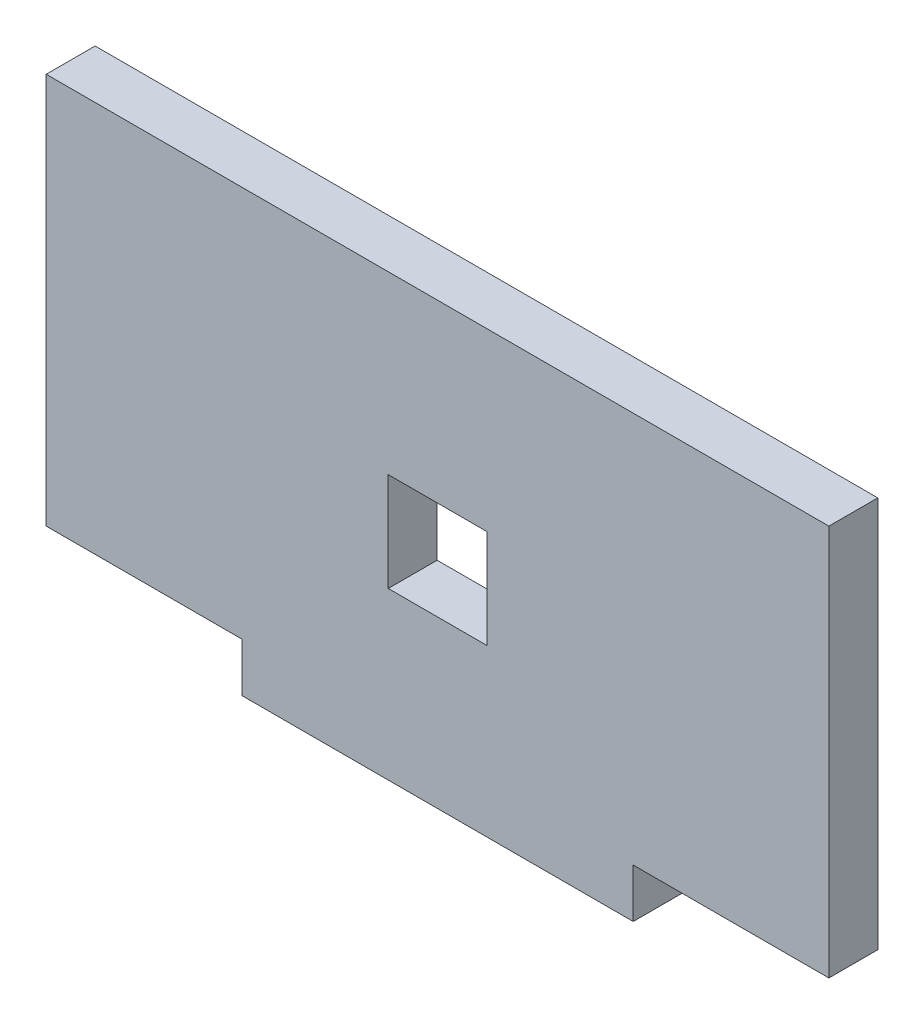
from build123d import *

# Parameters (mm, degrees)
SKETCH1_W           = 50.8
SKETCH1_H           = 28.575
BOSS_EXTRUDE1_DEPTH = 3.175
SKETCH2_W           = 12.7
SKETCH2_H           = 3.175
SKETCH2_W_2         = 6.4008
SKETCH2_H_2         = 6.4008
CUT_EXTRUDE1_DEPTH  = 3.175


with BuildPart() as part:
    # Sketch1 → Boss-Extrude1 (new body)
    with BuildSketch(Plane.XY):
        Rectangle(SKETCH1_W, SKETCH1_H)
    extrude(amount=BOSS_EXTRUDE1_DEPTH)

    # Sketch2 → Cut-Extrude1 (cut)
    with BuildSketch(Plane.XY.offset(3.175)):
        with Locations((-19.05, -12.7)):
            Rectangle(SKETCH2_W, SKETCH2_H)
        with Locations((19.05, -12.7)):
            Rectangle(SKETCH2_W, SKETCH2_H)
        with Locations((0, -0.3175)):
            Rectangle(SKETCH2_W_2, SKETCH2_H_2)
    extrude(amount=-CUT_EXTRUDE1_DEPTH, mode=Mode.SUBTRACT)


solid = part.part
